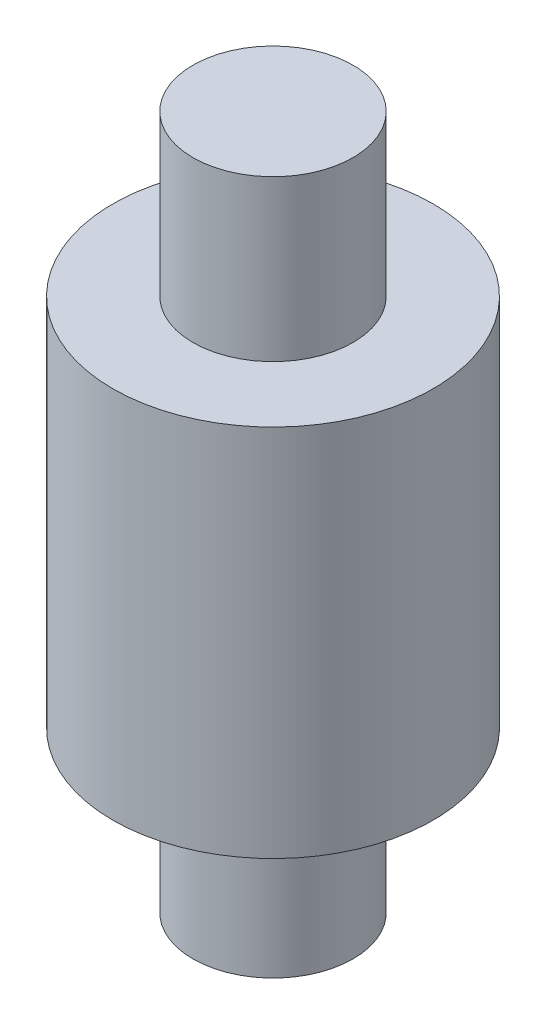
from build123d import *

# Parameters (mm, degrees)
SKETCH_1_R      = 3
EXTRUDE_1_DEPTH = 7
SKETCH_2_R      = 1.5
EXTRUDE_2_DEPTH = 3
SKETCH_3_R      = 1.5
EXTRUDE_3_DEPTH = 3


with BuildPart() as part:
    # Эскиз1 → Бобышка-Вытянуть1 (new body)
    with BuildSketch(Plane(origin=(0, 0, 0), x_dir=(1, 0, 0), z_dir=(0, 1, 0))):
        Circle(SKETCH_1_R)
    extrude(amount=EXTRUDE_1_DEPTH)

    # Эскиз2 → Бобышка-Вытянуть2 (add)
    with BuildSketch(Plane.XZ):
        Circle(SKETCH_2_R)
    extrude(amount=EXTRUDE_2_DEPTH)

    # Эскиз3 → Бобышка-Вытянуть3 (add)
    with BuildSketch(Plane(origin=(0, 7, 0), x_dir=(1, 0, 0), z_dir=(0, 1, 0))):
        Circle(SKETCH_3_R)
    extrude(amount=EXTRUDE_3_DEPTH)


solid = part.part
